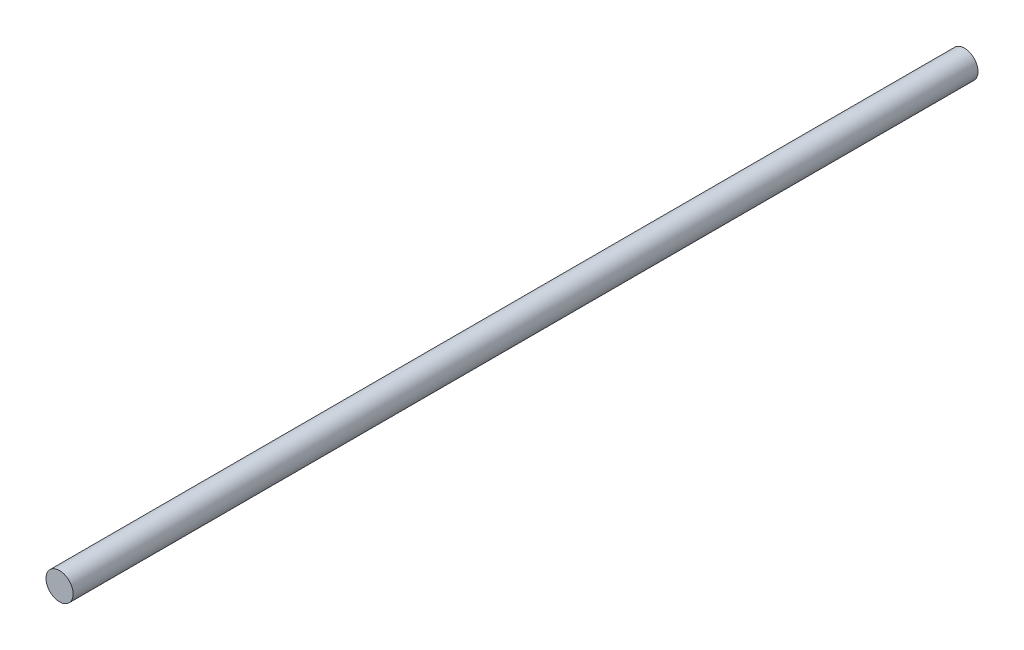
from build123d import *

# Parameters (mm, degrees)
CROQUIS1_R              = 0.762
SALIENTE_EXTRUIR1_DEPTH = 50.8


with BuildPart() as part:
    # Croquis1 → Saliente-Extruir1 (new body)
    with BuildSketch(Plane.XY):
        Circle(CROQUIS1_R)
    extrude(amount=SALIENTE_EXTRUIR1_DEPTH)


solid = part.part
